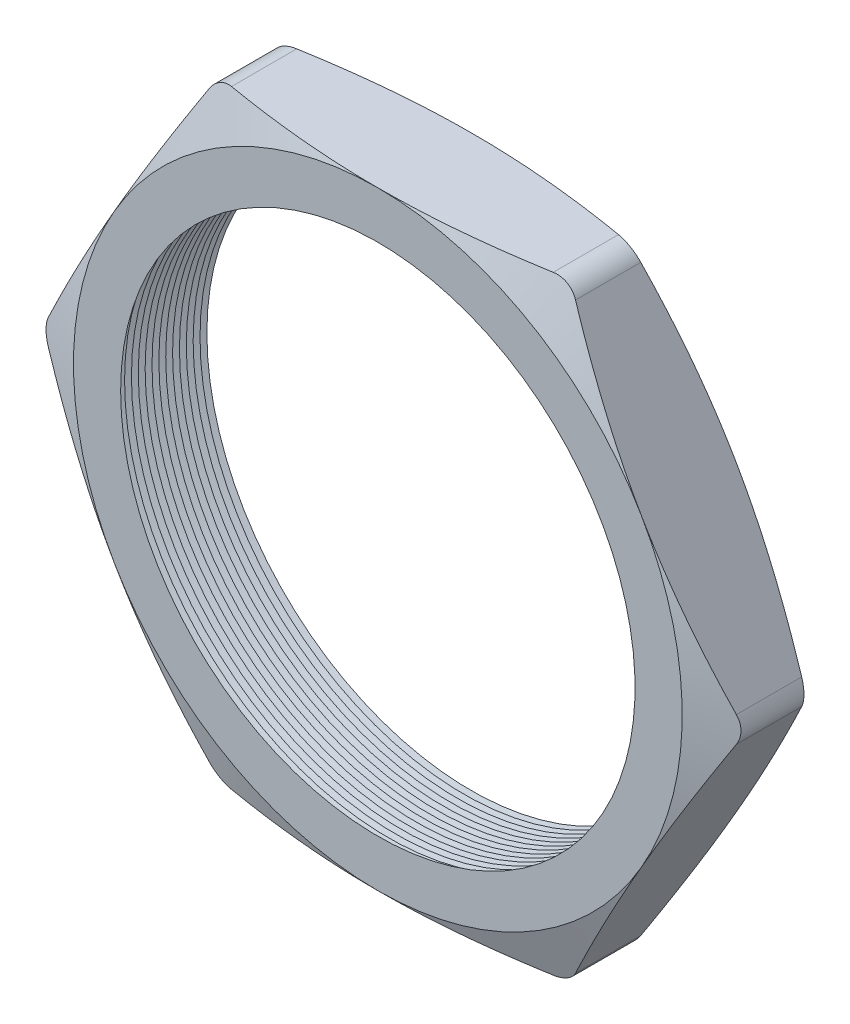
from build123d import *

# Parameters (mm, degrees)
SKETCH1_R          = 7.62
EXTRUDE1_DEPTH     = 2.794
FILLET1_R          = 0.762
SKETCH2_OUTSIDE_W  = 48.938
SKETCH2_OUTSIDE_H  = 46.384
SKETCH2_OUTSIDE_R  = 9.017
CUT_EXTRUDE1_DEPTH = 3.794
CUT_EXTRUDE1_DRAFT = -70
SKETCH3_OUTSIDE_W  = 48.938
SKETCH3_OUTSIDE_H  = 46.384
SKETCH3_OUTSIDE_R  = 9.017
CUT_EXTRUDE2_DEPTH = 3.7940001
CUT_EXTRUDE2_DRAFT = -70
LPATTERN1_COUNT    = 14
LPATTERN1_PITCH    = 0.2032


with BuildPart() as part:
    # Sketch1 → Extrude1 (new body)
    with BuildSketch(Plane.XY):
        Polygon((-10.411934755, 0), (-5.205967377, -9.017), (5.205967377, -9.017), (10.411934755, 0), (5.205967377, 9.017), (-5.205967377, 9.017), align=None)
        Circle(SKETCH1_R, mode=Mode.SUBTRACT)
    extrude(amount=EXTRUDE1_DEPTH)

    # Fillet1
    fillet1_edges = [part.edges().sort_by_distance(p)[0] for p in [
        (10.411934755, 0, 1.397),
        (5.205967377, -9.017, 1.397),
        (-5.205967377, -9.017, 1.397),
        (-10.411934755, 0, 1.397),
        (-5.205967377, 9.017, 1.397),
        (5.205967377, 9.017, 1.397),
    ]]
    fillet(fillet1_edges, radius=FILLET1_R)


with BuildPart() as cut_extrude1_tool:
    # Sketch2 outside → Cut-Extrude1 (with draft: the straight prism first)
    with BuildSketch(Plane.XY.offset(2.794)):
        Rectangle(SKETCH2_OUTSIDE_W, SKETCH2_OUTSIDE_H)
        Circle(SKETCH2_OUTSIDE_R, mode=Mode.SUBTRACT)
    extrude(amount=-CUT_EXTRUDE1_DEPTH)
    # Cut-Extrude1: the draft: its side faces are tilted about the plane it starts from
    cut_extrude1_sides = [cut_extrude1_tool.faces().sort_by_distance(p)[0] for p in [
        (0, -23.192, 0.897),
        (24.469, 0, 0.897),
        (0, 23.192, 0.897),
        (-24.469, 0, 0.897),
        (-9.017, 0, 0.897),
    ]]
    draft(cut_extrude1_sides, Plane.XY.offset(2.794), CUT_EXTRUDE1_DRAFT)


with BuildPart() as part_1:
    add(part.part)

    # Cut-Extrude1: cut by cut_extrude1_tool
    add(cut_extrude1_tool.part, mode=Mode.SUBTRACT)


with BuildPart() as cut_extrude2_tool:
    # Sketch3 outside → Cut-Extrude2 (with draft: the straight prism first)
    with BuildSketch(Plane(origin=(0, 0, 0), x_dir=(-1, 0, 0), z_dir=(0, 0, -1))):
        Rectangle(SKETCH3_OUTSIDE_W, SKETCH3_OUTSIDE_H)
        Circle(SKETCH3_OUTSIDE_R, mode=Mode.SUBTRACT)
    extrude(amount=-CUT_EXTRUDE2_DEPTH)
    # Cut-Extrude2: the draft: its side faces are tilted about the plane it starts from
    cut_extrude2_sides = [cut_extrude2_tool.faces().sort_by_distance(p)[0] for p in [
        (0, -23.192, 1.89700005),
        (-24.469, 0, 1.89700005),
        (0, 23.192, 1.89700005),
        (24.469, 0, 1.89700005),
        (9.017, 0, 1.89700005),
    ]]
    draft(cut_extrude2_sides, Plane(origin=(0, 0, 0), x_dir=(-1, 0, 0), z_dir=(0, 0, -1)), CUT_EXTRUDE2_DRAFT)


with BuildPart() as part_2:
    add(part_1.part)

    # Cut-Extrude2: cut by cut_extrude2_tool
    add(cut_extrude2_tool.part, mode=Mode.SUBTRACT)

    # Sketch4 → Cut-Revolve1 (revolve, cut)
    with BuildSketch(Plane(origin=(0, 0, 0), x_dir=(1, 0, 0), z_dir=(0, 1, 0))):
        Polygon((-7.62, -2.794), (-7.62, -2.354059095), (-8.001, -2.574029547), align=None)
    cut_revolve1 = revolve(axis=Axis((0, 0, 2.794), (0, 0, -1)), mode=Mode.SUBTRACT)

    # LPattern1: Cut-Revolve1 ×14
    with Locations(*[(0, 0, -i * LPATTERN1_PITCH) for i in range(1, LPATTERN1_COUNT)]):
        add(cut_revolve1, mode=Mode.SUBTRACT)


solid = part_2.part
